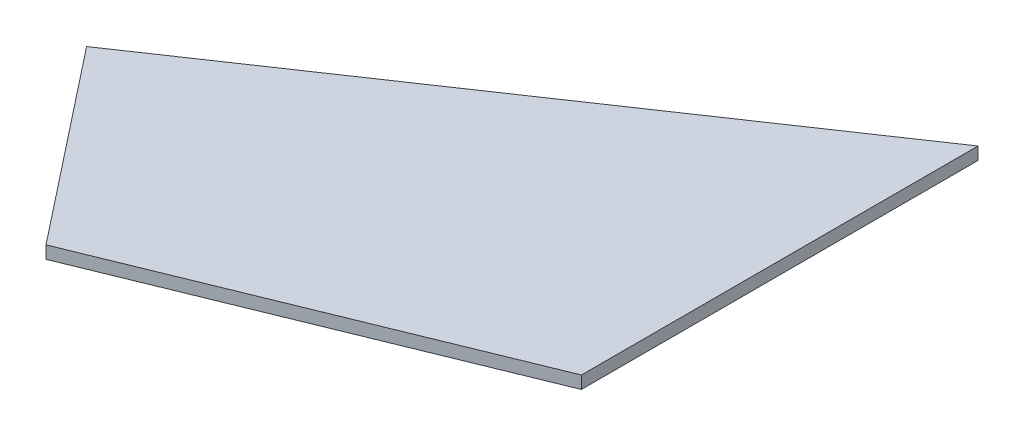
from build123d import *

# Parameters (mm, degrees)
BOSS_EXTRU_1_DEPTH = 2


with BuildPart() as part:
    # Esquisse1 → Boss.-Extru.1 (new body)
    with BuildSketch(Plane(origin=(0, 0, 0), x_dir=(1, 0, 0), z_dir=(0, 1, 0))):
        Polygon((60.595218653, 87.867559821), (-24.127539359, 30.592630228), (0, 0), (60.595218653, 24.690690244), align=None)
    extrude(amount=BOSS_EXTRU_1_DEPTH)


solid = part.part
